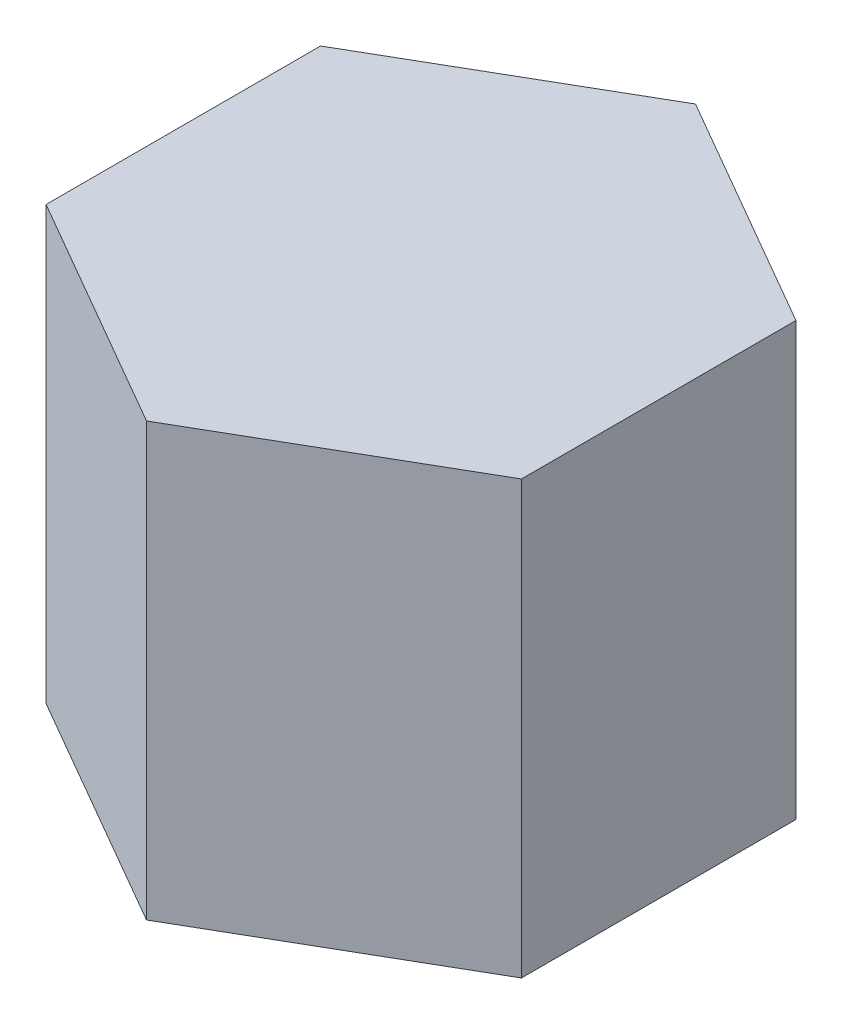
from build123d import *

# Parameters (mm, degrees)
BOSS_EXTRUDE1_DEPTH = 20


with BuildPart() as part:
    # Sketch1 → Boss-Extrude1 (new body)
    with BuildSketch(Plane(origin=(0, 0, 0), x_dir=(1, 0, 0), z_dir=(0, 1, 0))):
        Polygon((0, 12.701705922), (-11, 6.350852961), (-11, -6.350852961), (0, -12.701705922), (11, -6.350852961), (11, 6.350852961), align=None)
    extrude(amount=BOSS_EXTRUDE1_DEPTH)


solid = part.part
